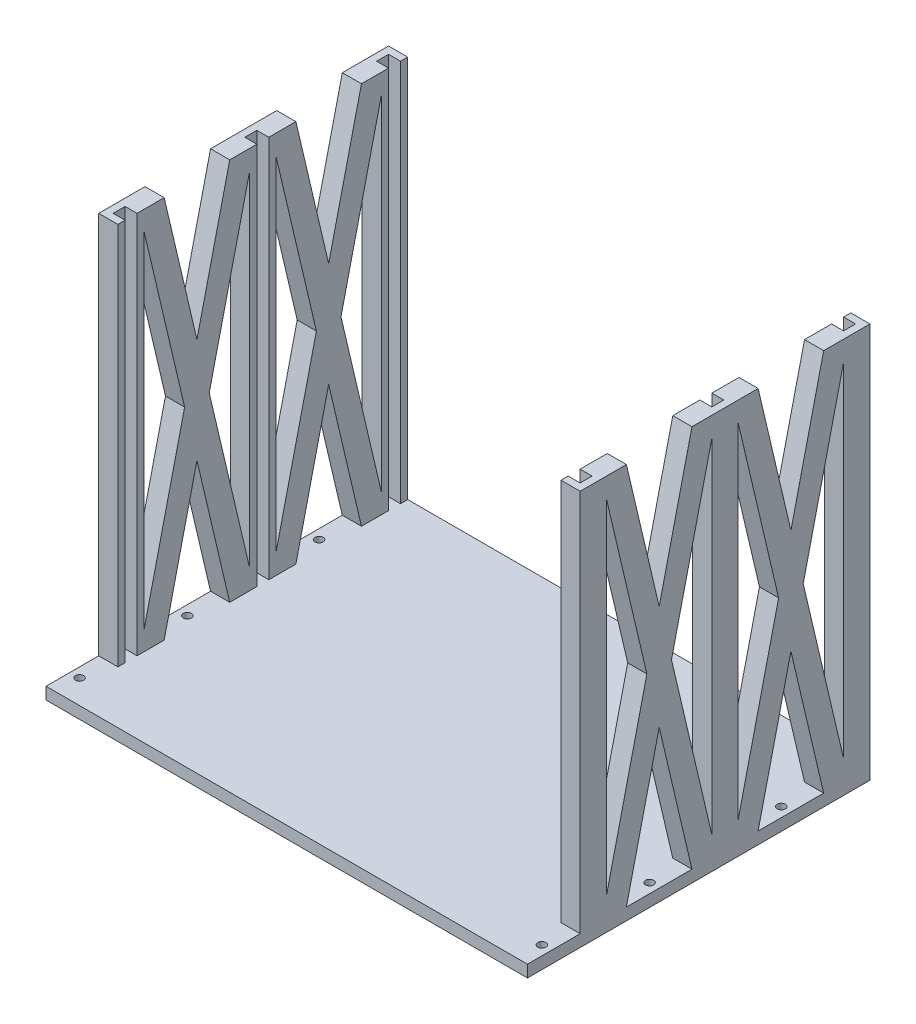
from build123d import *

# Parameters (mm, degrees)
BOSS_EXTRUDE1_DEPTH      = 160
BOSS_EXTRUDE1_2_DEPTH    = 160
LPATTERN1_COUNT          = 3
LPATTERN1_PITCH          = 55
SKETCH2_W                = 201
SKETCH2_H                = 143
BOSS_EXTRUDE2_DEPTH      = 5
BOSS_EXTRUDE3_DEPTH      = 8
M3_CLEARANCE_HOLE1_D     = 3.4
M3_CLEARANCE_HOLE1_DEPTH = 5


with BuildPart() as part:
    # Sketch1 → Boss-Extrude1 (new body)
    with BuildSketch(Plane(origin=(0, 0, 0), x_dir=(1, 0, 0), z_dir=(0, 1, 0))):
        Polygon((-100.5, 5.5), (-92.5, 5.5), (-92.5, 2.5), (-97.5, 2.5), (-97.5, -2.5), (-92.5, -2.5), (-92.5, -5.5), (-100.5, -5.5), align=None)
    boss_extrude1 = extrude(amount=BOSS_EXTRUDE1_DEPTH)



with BuildPart() as body_2:
    # Sketch1 → Boss-Extrude1 2 (new body)
    with BuildSketch(Plane(origin=(0, 0, 0), x_dir=(1, 0, 0), z_dir=(0, 1, 0))):
        Polygon((100.5, -5.5), (100.5, 5.5), (92.5, 5.5), (92.5, 2.5), (97.5, 2.5), (97.5, -2.5), (92.5, -2.5), (92.5, -5.5), align=None)
    boss_extrude1_2 = extrude(amount=BOSS_EXTRUDE1_2_DEPTH)


with BuildPart() as lpattern1_1:
    # LPattern1: pattern copy
    add(boss_extrude1.moved(Location(Vector(0, 0, 1) * (1 * LPATTERN1_PITCH))))


with BuildPart() as lpattern1_2:
    # LPattern1: pattern copy
    add(boss_extrude1.moved(Location(Vector(0, 0, 1) * (2 * LPATTERN1_PITCH))))


with BuildPart() as lpattern1_3:
    # LPattern1: pattern copy
    add(boss_extrude1_2.moved(Location(Vector(0, 0, 1) * (1 * LPATTERN1_PITCH))))


with BuildPart() as lpattern1_4:
    # LPattern1: pattern copy
    add(boss_extrude1_2.moved(Location(Vector(0, 0, 1) * (2 * LPATTERN1_PITCH))))


with BuildPart() as part_1:
    add(part.part)

    add(body_2.part)  # Boss-Extrude2 merges body 2

    add(lpattern1_1.part)  # Boss-Extrude2 merges LPattern1_1

    add(lpattern1_2.part)  # Boss-Extrude2 merges LPattern1_2

    add(lpattern1_3.part)  # Boss-Extrude2 merges LPattern1_3

    add(lpattern1_4.part)  # Boss-Extrude2 merges LPattern1_4
    # Sketch2 → Boss-Extrude2 (add)
    with BuildSketch(Plane.XZ):
        with Locations((0, 66)):
            Rectangle(SKETCH2_W, SKETCH2_H)
    extrude(amount=BOSS_EXTRUDE2_DEPTH)

    # Sketch3 → Boss-Extrude3 (add)
    with BuildSketch(Plane.ZY.offset(100.5)):
        Polygon((5.5, 160), (13.816526412, 160), (27.5, 101.834227561), (41.183473588, 160), (49.5, 160), (49.5, 151.683473588), (32.636492883, 80), (49.5, 8.316526412), (49.5, 0), (41.183473588, 0), (27.5, 58.165772439), (13.816526412, 0), (5.5, 0), (5.5, 8.316526412), (22.363507117, 80), (5.5, 151.683473588), align=None)
        Polygon((104.5, 151.683473588), (104.5, 160), (96.183473588, 160), (82.5, 101.834227561), (68.816526412, 160), (60.5, 160), (60.5, 151.683473588), (77.363507117, 80), (60.5, 8.316526412), (60.5, 0), (68.816526412, 0), (82.5, 58.165772439), (96.183473588, 0), (104.5, 0), (104.5, 8.316526412), (87.636492883, 80), align=None)
    boss_extrude3 = extrude(amount=-BOSS_EXTRUDE3_DEPTH)

    # Mirror1: Boss-Extrude3 across plane
    add(boss_extrude3.mirror(Plane(origin=(0, 0, 0), x_dir=(0, 0, 1), z_dir=(1, 0, 0))))

    # M3 Clearance Hole1
    with Locations(Plane(origin=(0, 0, 0), x_dir=(1, 0, 0), z_dir=(0, 1, 0))):
        with Locations((-96.5, -27.5), (-96.5, -82.5), (96.5, -82.5), (96.5, -27.5), (-96.5, -127.5), (96.5, -127.5)):
            Hole(M3_CLEARANCE_HOLE1_D / 2, depth=M3_CLEARANCE_HOLE1_DEPTH)


solid = part_1.part
